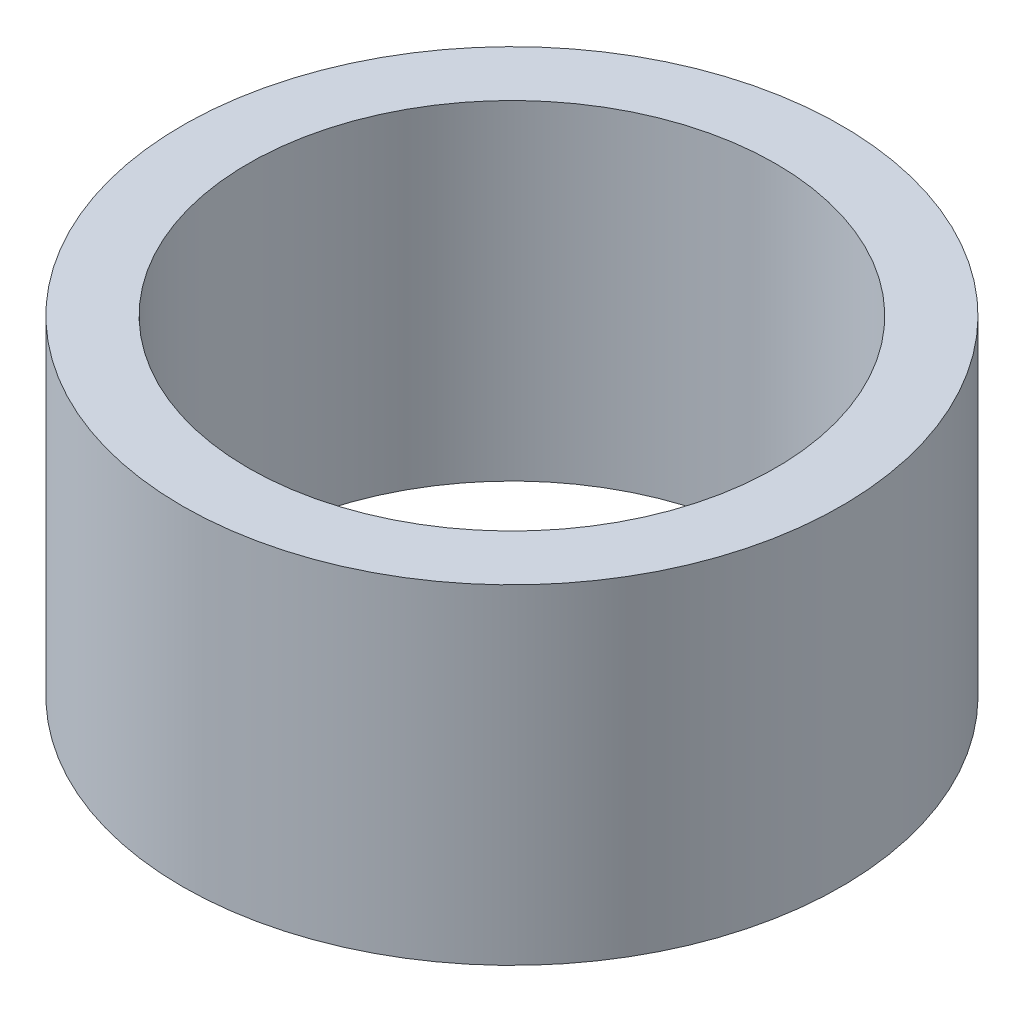
from build123d import *

# Parameters (mm, degrees)
SKETCH_1_R      = 20
SKETCH_1_R_2    = 16
EXTRUDE_1_DEPTH = 20


with BuildPart() as part:
    # 草图1 → 凸台-拉伸1 (new body)
    with BuildSketch(Plane(origin=(0, 0, 0), x_dir=(1, 0, 0), z_dir=(0, 1, 0))):
        Circle(SKETCH_1_R)
        Circle(SKETCH_1_R_2, mode=Mode.SUBTRACT)
    extrude(amount=EXTRUDE_1_DEPTH)


solid = part.part
